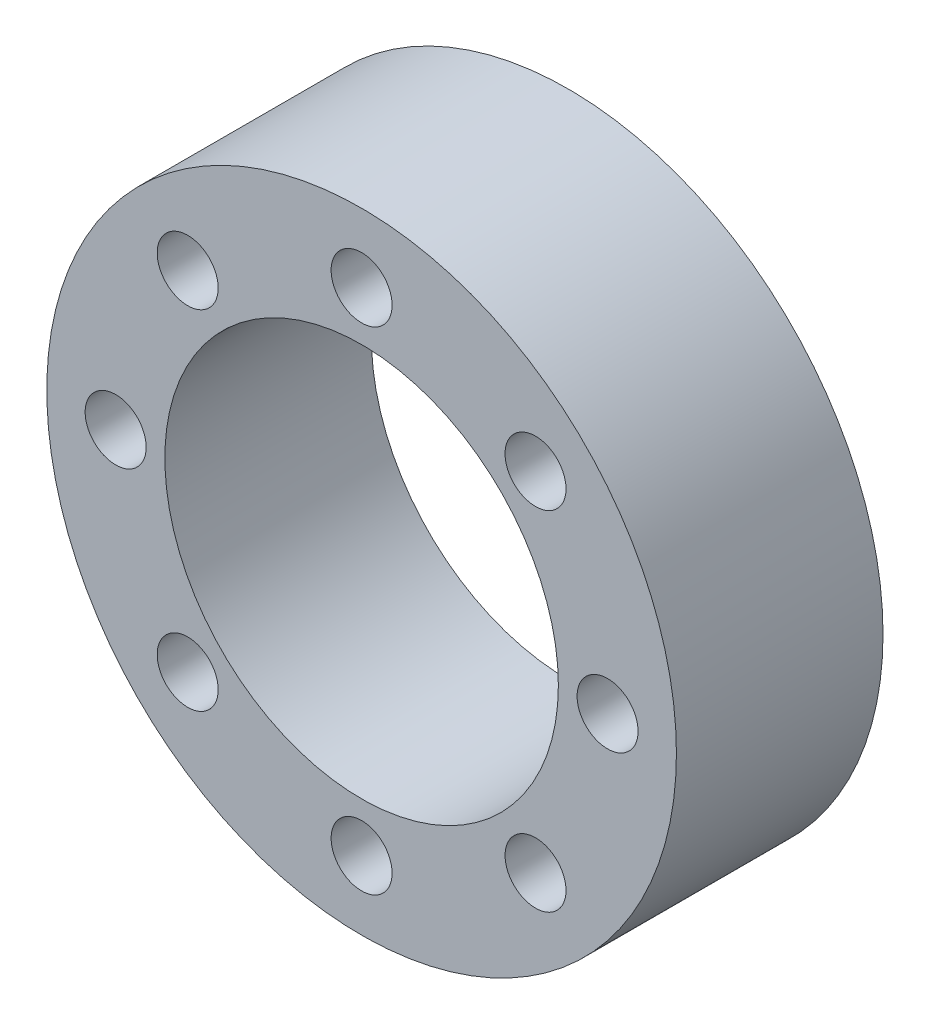
from build123d import *

# Parameters (mm, degrees)
SKETCH_1_R      = 16
SKETCH_1_R_2    = 1.55
SKETCH_1_R_3    = 10
EXTRUDE_1_DEPTH = 10.5


with BuildPart() as part:
    # 草图1 → 凸台-拉伸1 (new body)
    with BuildSketch(Plane.XY):
        Circle(SKETCH_1_R)
        with Locations((0, 12.5)):
            Circle(SKETCH_1_R_2, mode=Mode.SUBTRACT)
        with Locations((8.838834765, 8.838834765)):
            Circle(SKETCH_1_R_2, mode=Mode.SUBTRACT)
        with Locations((12.5, 0)):
            Circle(SKETCH_1_R_2, mode=Mode.SUBTRACT)
        with Locations((8.838834765, -8.838834765)):
            Circle(SKETCH_1_R_2, mode=Mode.SUBTRACT)
        with Locations((0, -12.5)):
            Circle(SKETCH_1_R_2, mode=Mode.SUBTRACT)
        with Locations((-8.838834765, -8.838834765)):
            Circle(SKETCH_1_R_2, mode=Mode.SUBTRACT)
        with Locations((-12.5, 0)):
            Circle(SKETCH_1_R_2, mode=Mode.SUBTRACT)
        with Locations((-8.838834765, 8.838834765)):
            Circle(SKETCH_1_R_2, mode=Mode.SUBTRACT)
        Circle(SKETCH_1_R_3, mode=Mode.SUBTRACT)
    extrude(amount=EXTRUDE_1_DEPTH)


solid = part.part
